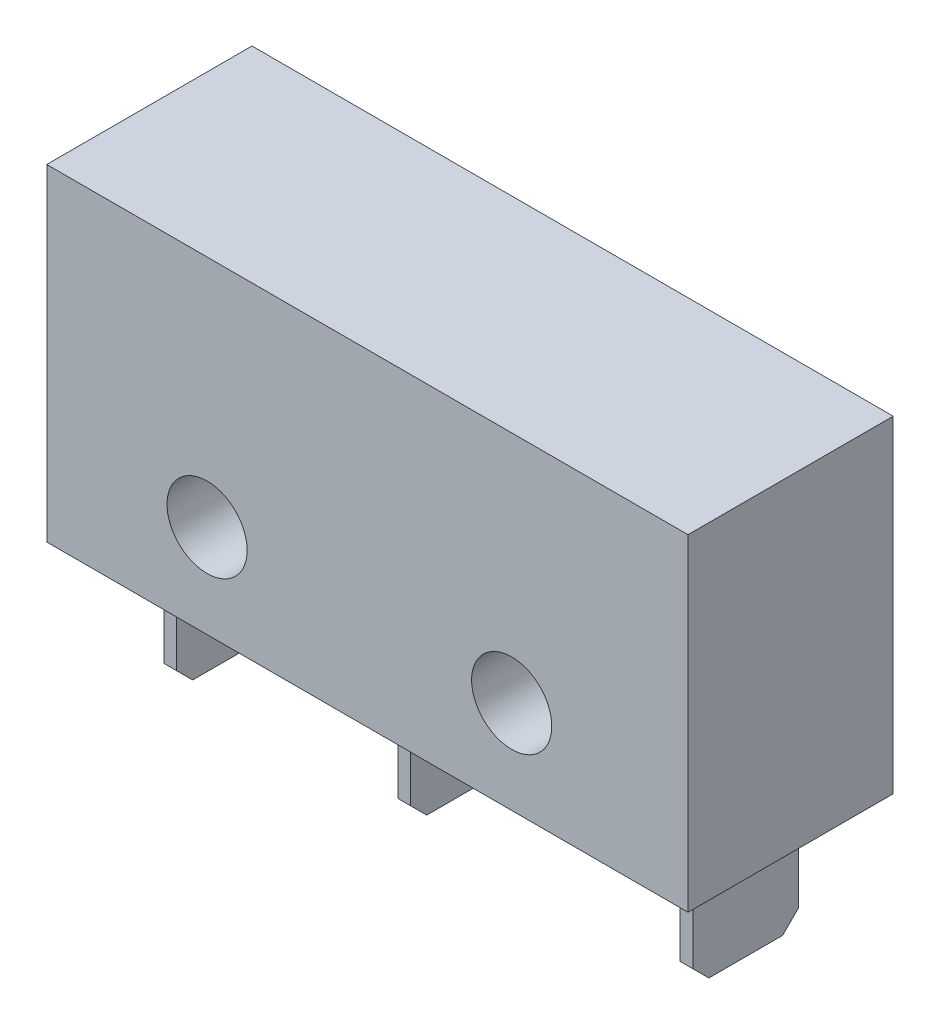
from build123d import *

# Parameters (mm, degrees)
SKETCH1_W           = 20
SKETCH1_H           = 10.2
BOSS_EXTRUDE1_DEPTH = 6.4
SKETCH2_W           = 0.4
SKETCH2_H           = 3.3
BOSS_EXTRUDE2_DEPTH = 3.5
CUT_EXTRUDE1_REACH  = 8.4
SKETCH3_R           = 1.25
CHAMFER1_SIZE       = 0.5


with BuildPart() as part:
    # Sketch1 → Boss-Extrude1 (new body)
    with BuildSketch(Plane.XY):
        with Locations((10, 5.1)):
            Rectangle(SKETCH1_W, SKETCH1_H)
    extrude(amount=BOSS_EXTRUDE1_DEPTH)

    # Sketch2 → Boss-Extrude2 (add)
    with BuildSketch(Plane.XZ):
        with Locations((18.4, 3.2)):
            Rectangle(SKETCH2_W, SKETCH2_H)
        with Locations((9.6, 3.2)):
            Rectangle(SKETCH2_W, SKETCH2_H)
        with Locations((2.3, 3.2)):
            Rectangle(SKETCH2_W, SKETCH2_H)
    extrude(amount=BOSS_EXTRUDE2_DEPTH)

    # Sketch3 → Cut-Extrude1 (cut, up to next)
    with BuildSketch(Plane.XY.offset(6.4), mode=Mode.PRIVATE) as cut_extrude1_sk1:
        with Locations((14.5, 2.9)):
            Circle(SKETCH3_R)
    cut_extrude1_tool1 = extrude(cut_extrude1_sk1.sketch, amount=-CUT_EXTRUDE1_REACH, mode=Mode.PRIVATE) & part.part
    add(cut_extrude1_tool1.solids().sort_by_distance((14.5, 2.9, 6.4))[0], mode=Mode.SUBTRACT)
    # Sketch3 → Cut-Extrude1 (cut, up to next)
    with BuildSketch(Plane.XY.offset(6.4), mode=Mode.PRIVATE) as cut_extrude1_sk2:
        with Locations((5, 2.9)):
            Circle(SKETCH3_R)
    cut_extrude1_tool2 = extrude(cut_extrude1_sk2.sketch, amount=-CUT_EXTRUDE1_REACH, mode=Mode.PRIVATE) & part.part
    add(cut_extrude1_tool2.solids().sort_by_distance((5, 2.9, 6.4))[0], mode=Mode.SUBTRACT)

    # Chamfer1
    chamfer1_edges = [part.edges().sort_by_distance(p)[0] for p in [
        (18.4, -3.5, 1.55),
        (18.4, -3.5, 4.85),
        (9.6, -3.5, 1.55),
        (9.6, -3.5, 4.85),
        (2.3, -3.5, 1.55),
        (2.3, -3.5, 4.85),
    ]]
    chamfer(chamfer1_edges, length=CHAMFER1_SIZE)


solid = part.part
